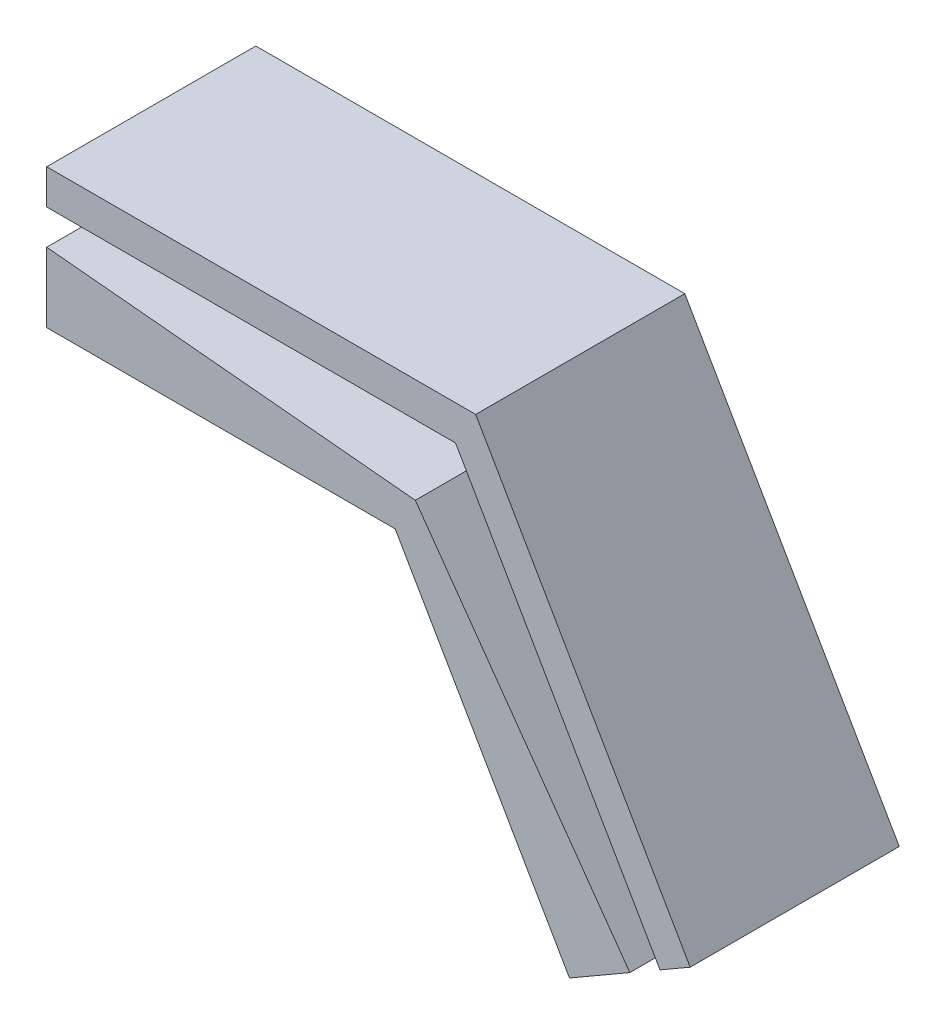
from build123d import *

# Parameters (mm, degrees)
SALIENTE_EXTRUIR1_DEPTH = 6
CORTAR_EXTRUIR1_DEPTH   = 5


with BuildPart() as part:
    # Croquis1 → Saliente-Extruir1 (new body)
    with BuildSketch(Plane.XY):
        Polygon((-111.668383112, 35.923858733), (-101.668383112, 35.923858733), (-96.668383112, 27.263604695), (-93.204281497, 29.263604695), (-99.358982036, 39.923858733), (-111.668383112, 39.923858733), align=None)
    extrude(amount=SALIENTE_EXTRUIR1_DEPTH)

    # Croquis2 → Cortar-Extruir1 (cut)
    with BuildSketch(Plane.XY.offset(6)):
        Polygon((-111.668383112, 37.923858733), (-111.668383112, 38.923858733), (-99.936332305, 38.923858733), (-94.070306901, 28.763604695), (-94.936332305, 28.263604695), (-101.091032843, 36.923858733), align=None)
    extrude(amount=-CORTAR_EXTRUIR1_DEPTH, mode=Mode.SUBTRACT)


solid = part.part
